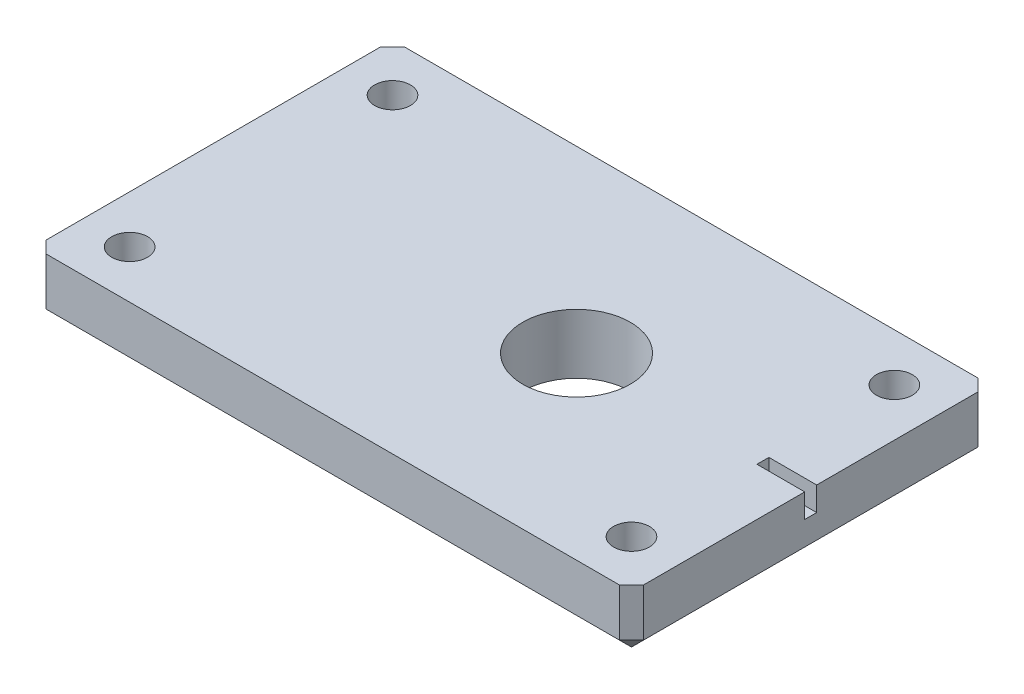
from build123d import *

# Parameters (mm, degrees)
SKETCH1_W           = 50
SKETCH1_H           = 30
BOSS_EXTRUDE1_DEPTH = 5
SKETCH2_W           = 4
SKETCH2_H           = 1
CUT_EXTRUDE1_DEPTH  = 2
SKETCH3_R           = 4.5
CUT_EXTRUDE2_DEPTH  = 22
SKETCH3_3_R         = 4.5
SKETCH3_3_R_2       = 1.5
CUT_EXTRUDE3_DEPTH  = 22
CHAMFER1_SIZE       = 1


with BuildPart() as part:
    # Sketch1 → Boss-Extrude1 (new body)
    with BuildSketch(Plane(origin=(0, 0, 0), x_dir=(1, 0, 0), z_dir=(0, 1, 0))):
        Rectangle(SKETCH1_W, SKETCH1_H)
    extrude(amount=BOSS_EXTRUDE1_DEPTH)

    # Sketch2 → Cut-Extrude1 (cut)
    with BuildSketch(Plane(origin=(0, 5, 0), x_dir=(1, 0, 0), z_dir=(0, 1, 0))):
        with Locations((23, 0)):
            Rectangle(SKETCH2_W, SKETCH2_H)
    extrude(amount=-CUT_EXTRUDE1_DEPTH, mode=Mode.SUBTRACT)

    # Sketch3 → Cut-Extrude2 (cut)
    with BuildSketch(Plane(origin=(0, 5, 0), x_dir=(1, 0, 0), z_dir=(0, 1, 0))):
        with Locations((5.4, 0)):
            Circle(SKETCH3_R)
    extrude(amount=-CUT_EXTRUDE2_DEPTH, mode=Mode.SUBTRACT)

    # Sketch3_3 → Cut-Extrude3 (cut)
    with BuildSketch(Plane(origin=(0, 5, 0), x_dir=(1, 0, 0), z_dir=(0, 1, 0))):
        with Locations((5.4, 0)):
            Circle(SKETCH3_3_R)
        with Locations((-21, 11)):
            Circle(SKETCH3_3_R_2)
        with Locations((21, 11)):
            Circle(SKETCH3_3_R_2)
        with Locations((21, -11)):
            Circle(SKETCH3_3_R_2)
        with Locations((-21, -11)):
            Circle(SKETCH3_3_R_2)
    extrude(amount=-CUT_EXTRUDE3_DEPTH, mode=Mode.SUBTRACT)

    # Chamfer1
    chamfer1_edges = [part.edges().sort_by_distance(p)[0] for p in [
        (-25, 2.5, -15),
        (-25, 2.5, 15),
        (25, 2.5, 15),
        (25, 2.5, -15),
        (-25, 0, 0),
        (0, 0, 15),
        (25, 0, 0),
        (0, 0, -15),
    ]]
    chamfer(chamfer1_edges, length=CHAMFER1_SIZE)


solid = part.part
